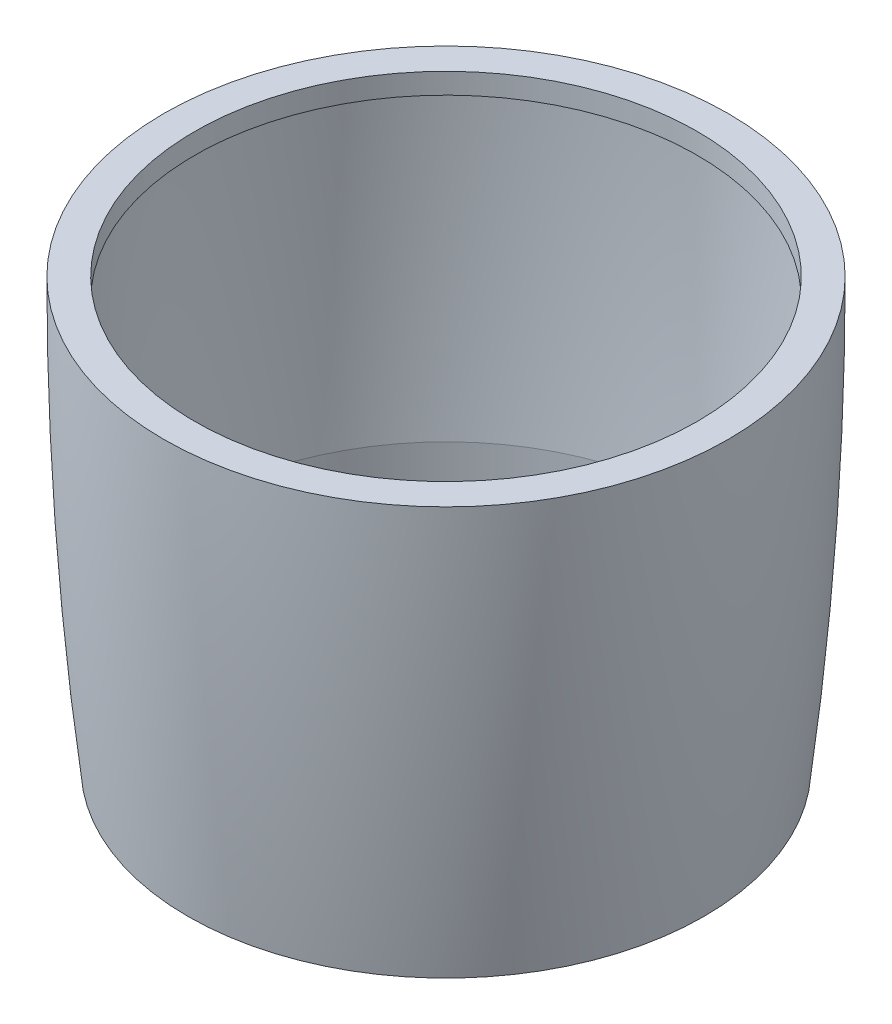
from build123d import *


with BuildPart() as part:
    # Sketch1 → Revolve1 (revolve)
    with BuildSketch(Plane.XY):
        with BuildLine():
            Line((-20.5, 0), (-18.25, 0))
            Line((-18.25, 0), (-18.25, -1.5))
            Line((-18.25, -1.5), (-19.245865417, -1.5))
            ThreePointArc((-19.245865417, -1.5), (-18.966701987, -12.413256916), (-18.25, -23.306532227))
            Line((-18.25, -23.306532227), (-18.25, -30.881269044))
            Line((-18.25, -30.881269044), (-18.75, -30.881269044))
            ThreePointArc((-18.75, -30.881269044), (-20.062149323, -15.465407187), (-20.5, 0))
        make_face()
    revolve(axis=Axis((0, -1072.800260621, 0), (0, 1, 0)))


solid = part.part
